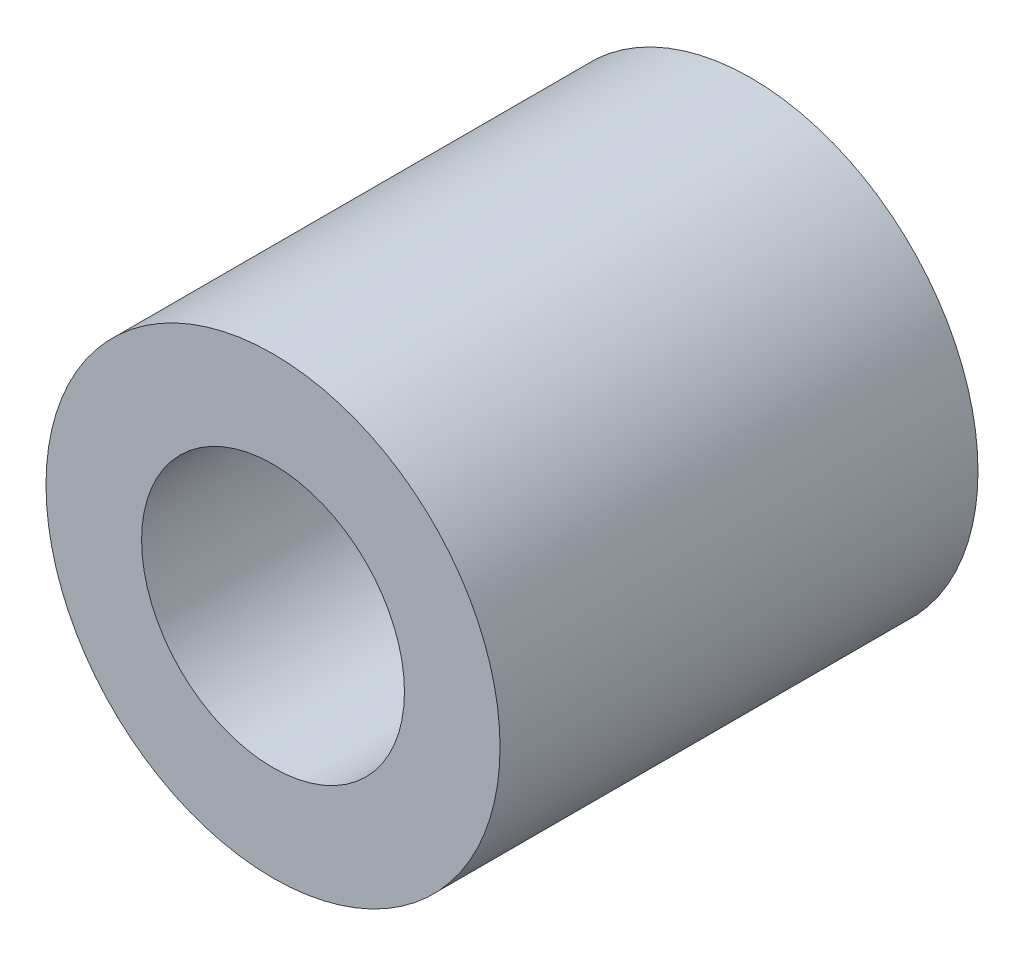
from build123d import *

# Parameters (mm, degrees)
CROQUIS1_R              = 4.75
CROQUIS1_R_2            = 2.75
SALIENTE_EXTRUIR1_DEPTH = 10


with BuildPart() as part:
    # Croquis1 → Saliente-Extruir1 (new body)
    with BuildSketch(Plane.XY):
        Circle(CROQUIS1_R)
        Circle(CROQUIS1_R_2, mode=Mode.SUBTRACT)
    extrude(amount=SALIENTE_EXTRUIR1_DEPTH)


solid = part.part
